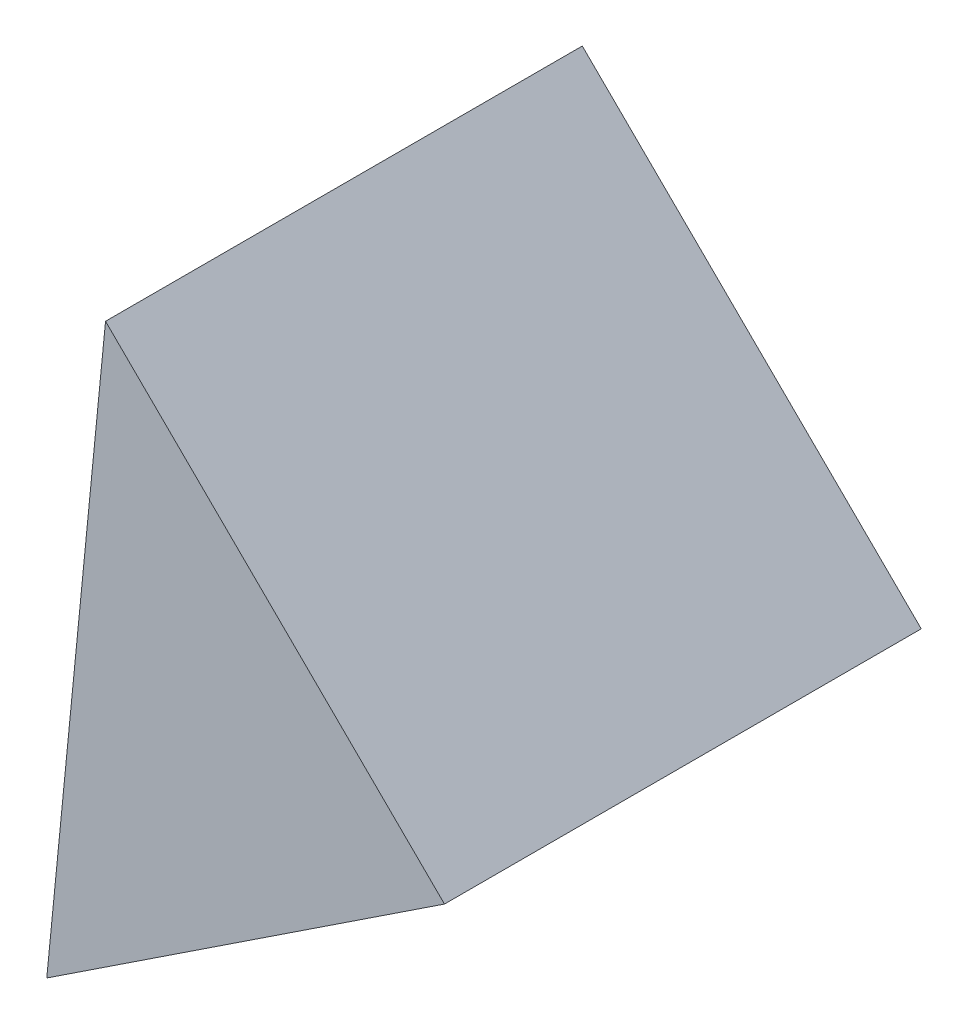
from build123d import *

# Parameters (mm, degrees)
EXTRUDE_1_DEPTH = 25


with BuildPart() as part:
    # 草图2 → 凸台-拉伸1 (new body)
    with BuildSketch(Plane.XY):
        Polygon((21.542170668, 14.632509255), (3.767850077, 32.21299638), (0.686170974, 0.847471105), align=None)
    extrude(amount=EXTRUDE_1_DEPTH)


solid = part.part
